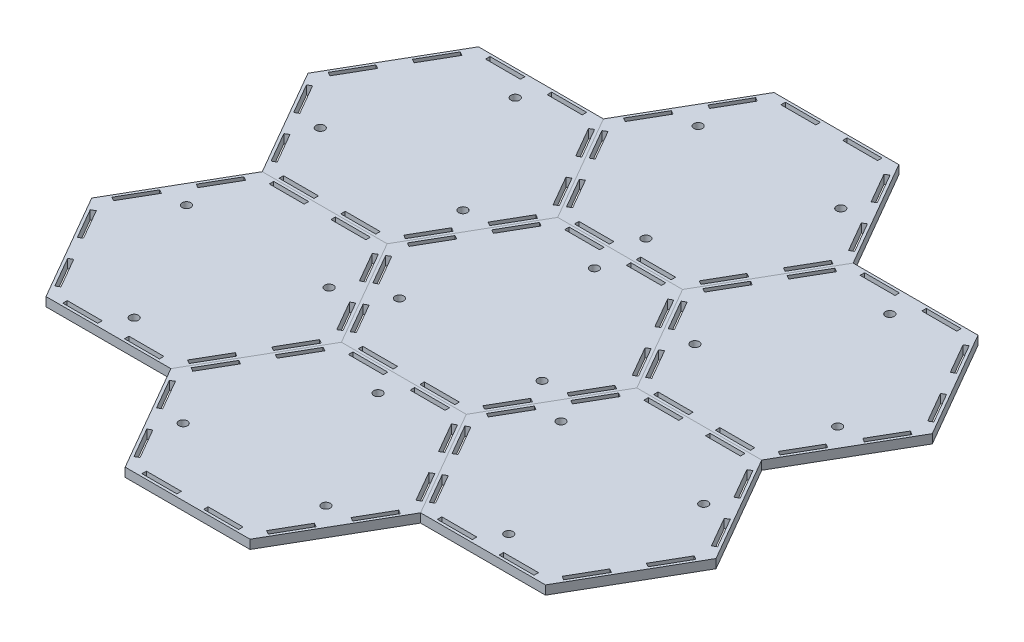
from build123d import *

# Parameters (mm, degrees)
BOSS_EXTRUDE1_DEPTH = 6.35
SKETCH2_R           = 3.0734
SKETCH2_W           = 24.892
SKETCH2_H           = 3.175
CUT_EXTRUDE1_DEPTH  = 118.774954893
CIRPATTERN1_COUNT   = 6


with BuildPart() as part:
    # Sketch1 → Boss-Extrude1 (new body)
    with BuildSketch(Plane(origin=(0, 0, 0), x_dir=(1, 0, 0), z_dir=(0, 1, 0))):
        Polygon((-88.9, 0), (-44.45, -76.989658396), (44.45, -76.989658396), (88.9, 0), (44.45, 76.989658396), (-44.45, 76.989658396), align=None)
    extrude(amount=BOSS_EXTRUDE1_DEPTH)

    # Sketch2 → Cut-Extrude1 (cut, through all)
    with BuildSketch(Plane(origin=(0, 6.35, 0), x_dir=(1, 0, 0), z_dir=(0, 1, 0))):
        with Locations((-50.8, -29.329393675)):
            Circle(SKETCH2_R)
        with Locations((0, 58.65878735)):
            Circle(SKETCH2_R)
        with Locations((50.8, -29.329393675)):
            Circle(SKETCH2_R)
        Polygon((-79.484090949, -6.148832876), (-82.233721606, -7.736332876), (-69.787721606, -29.293437227), (-67.038090949, -27.705937227), align=None)
        Polygon((-45.067090949, -65.76082552), (-47.816721606, -67.34832552), (-60.262721606, -45.791221169), (-57.513090949, -44.203721169), align=None)
        Polygon((-45.067090949, 65.76082552), (-47.816721606, 67.34832552), (-60.262721606, 45.791221169), (-57.513090949, 44.203721169), align=None)
        Polygon((-69.787721606, 29.293437227), (-67.038090949, 27.705937227), (-79.484090949, 6.148832876), (-82.233721606, 7.736332876), align=None)
        with Locations((21.971, 73.497158396)):
            Rectangle(SKETCH2_W, SKETCH2_H)
        with Locations((-21.971, 73.497158396)):
            Rectangle(SKETCH2_W, SKETCH2_H)
        Polygon((79.484090949, 6.148832876), (82.233721606, 7.736332876), (69.787721606, 29.293437227), (67.038090949, 27.705937227), align=None)
        Polygon((60.262721606, 45.791221169), (57.513090949, 44.203721169), (45.067090949, 65.76082552), (47.816721606, 67.34832552), align=None)
        Polygon((45.067090949, -65.76082552), (47.816721606, -67.34832552), (60.262721606, -45.791221169), (57.513090949, -44.203721169), align=None)
        Polygon((69.787721606, -29.293437227), (67.038090949, -27.705937227), (79.484090949, -6.148832876), (82.233721606, -7.736332876), align=None)
        with Locations((-21.971, -73.497158396)):
            Rectangle(SKETCH2_W, SKETCH2_H)
        with Locations((21.971, -73.497158396)):
            Rectangle(SKETCH2_W, SKETCH2_H)
    extrude(amount=-CUT_EXTRUDE1_DEPTH, mode=Mode.SUBTRACT)


with BuildPart() as body_2:
    # Mirror1: mirrored copy
    add(part.part.mirror(Plane(origin=(44.45, 6.35, 76.989658396), x_dir=(-0.5000000000000006, 0, 0.8660254037844384), z_dir=(-0.8660254037844385, 0, -0.5000000000000004))))


with BuildPart() as cirpattern1_1:
    # CirPattern1: pattern copy
    add(body_2.part.rotate(Axis((0, 0, 0), (0, 1, 0)), 1 * 360 / CIRPATTERN1_COUNT))


with BuildPart() as cirpattern1_2:
    # CirPattern1: pattern copy
    add(body_2.part.rotate(Axis((0, 0, 0), (0, 1, 0)), 2 * 360 / CIRPATTERN1_COUNT))


with BuildPart() as cirpattern1_3:
    # CirPattern1: pattern copy
    add(body_2.part.rotate(Axis((0, 0, 0), (0, 1, 0)), 3 * 360 / CIRPATTERN1_COUNT))


with BuildPart() as cirpattern1_4:
    # CirPattern1: pattern copy
    add(body_2.part.rotate(Axis((0, 0, 0), (0, 1, 0)), 4 * 360 / CIRPATTERN1_COUNT))


with BuildPart() as cirpattern1_5:
    # CirPattern1: pattern copy
    add(body_2.part.rotate(Axis((0, 0, 0), (0, 1, 0)), 5 * 360 / CIRPATTERN1_COUNT))


solid = Compound([part.part, body_2.part, cirpattern1_1.part, cirpattern1_2.part, cirpattern1_3.part, cirpattern1_4.part, cirpattern1_5.part])
